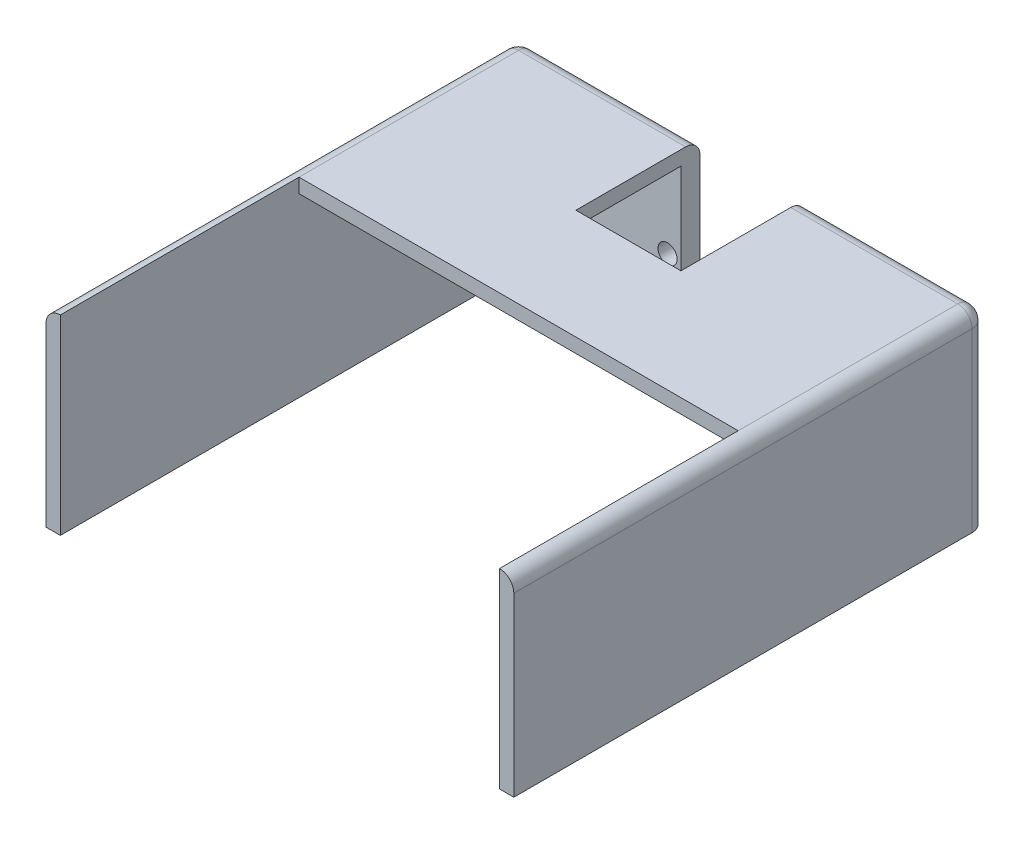
from build123d import *

# Parameters (mm, degrees)
CROQUIS2_W                = 92
CROQUIS2_H                = 40
SALIENTE_EXTRUIR2_DEPTH   = 4
CROQUIS3_W                = 3
CROQUIS3_H                = 40
SALIENTE_EXTRUIR3_DEPTH   = 95
SALIENTE_EXTRUIR3_2_DEPTH = 95
CROQUIS4_W                = 3
CROQUIS4_H                = 40
SALIENTE_EXTRUIR4_DEPTH   = 4
REDONDEO1_R               = 3
CROQUIS5_W                = 92
CROQUIS5_H                = 3
SALIENTE_EXTRUIR5_DEPTH   = 45
REDONDEO2_R               = 3
CROQUIS6_W                = 22
CROQUIS6_H                = 30
CORTAR_EXTRUIR1_DEPTH     = 26
CROQUIS7_R                = 2
CORTAR_EXTRUIR2_DEPTH     = 10


with BuildPart() as part:
    # Croquis2 → Saliente-Extruir2 (new body)
    with BuildSketch(Plane.XY):
        Rectangle(CROQUIS2_W, CROQUIS2_H)
    extrude(amount=SALIENTE_EXTRUIR2_DEPTH)



with BuildPart() as body_2:
    # Croquis3 → Saliente-Extruir3 (new body)
    with BuildSketch(Plane.XY.offset(4)):
        with Locations((-47.5, 0)):
            Rectangle(CROQUIS3_W, CROQUIS3_H)
    extrude(amount=SALIENTE_EXTRUIR3_DEPTH)


with BuildPart() as body_3:
    # Croquis3 → Saliente-Extruir3 2 (new body)
    with BuildSketch(Plane.XY.offset(4)):
        with Locations((47.5, 0)):
            Rectangle(CROQUIS3_W, CROQUIS3_H)
    extrude(amount=SALIENTE_EXTRUIR3_2_DEPTH)


with BuildPart() as part_1:
    add(part.part)

    add(body_2.part)  # Saliente-Extruir4 merges body 2

    add(body_3.part)  # Saliente-Extruir4 merges body 3
    # Croquis4 → Saliente-Extruir4 (add)
    with BuildSketch(Plane(origin=(0, 0, 4), x_dir=(-1, 0, 0), z_dir=(0, 0, -1))):
        with Locations((-47.5, 0)):
            Rectangle(CROQUIS4_W, CROQUIS4_H)
        with Locations((47.5, 0)):
            Rectangle(CROQUIS4_W, CROQUIS4_H)
    extrude(amount=SALIENTE_EXTRUIR4_DEPTH)

    # Redondeo1
    redondeo1_edges = [part_1.edges().sort_by_distance(p)[0] for p in [
        (49, 0, 0),
        (-49, 0, 0),
    ]]
    fillet(redondeo1_edges, radius=REDONDEO1_R)

    # Croquis5 → Saliente-Extruir5 (add)
    with BuildSketch(Plane.XY.offset(4)):
        with Locations((0, 18.5)):
            Rectangle(CROQUIS5_W, CROQUIS5_H)
    extrude(amount=SALIENTE_EXTRUIR5_DEPTH)

    # Redondeo2
    redondeo2_edges = [part_1.edges().sort_by_distance(p)[0] for p in [
        (-48.121320344, 20, 0.878679656),
        (0, 20, 0),
        (48.121320344, 20, 0.878679656),
        (-49, 20, 51),
        (49, 20, 51),
    ]]
    fillet(redondeo2_edges, radius=REDONDEO2_R)

    # Croquis6 → Cortar-Extruir1 (cut)
    with BuildSketch(Plane(origin=(0, 0, 0), x_dir=(-1, 0, 0), z_dir=(0, 0, -1))):
        with Locations((0, 5)):
            Rectangle(CROQUIS6_W, CROQUIS6_H)
    extrude(amount=-CORTAR_EXTRUIR1_DEPTH, mode=Mode.SUBTRACT)

    # Croquis7 → Cortar-Extruir2 (cut)
    with BuildSketch(Plane(origin=(0, 0, 0), x_dir=(-1, 0, 0), z_dir=(0, 0, -1))):
        with Locations((5, -15)):
            Circle(CROQUIS7_R)
        with Locations((-5, -15)):
            Circle(CROQUIS7_R)
        with Locations((13.733587387, -10.3)):
            Circle(CROQUIS7_R)
        with Locations((-13.733587387, -10.3)):
            Circle(CROQUIS7_R)
        with Locations((13.8, -0.300220534)):
            Circle(CROQUIS7_R)
        with Locations((-13.8, -0.300220534)):
            Circle(CROQUIS7_R)
    extrude(amount=-CORTAR_EXTRUIR2_DEPTH, mode=Mode.SUBTRACT)


solid = part_1.part
